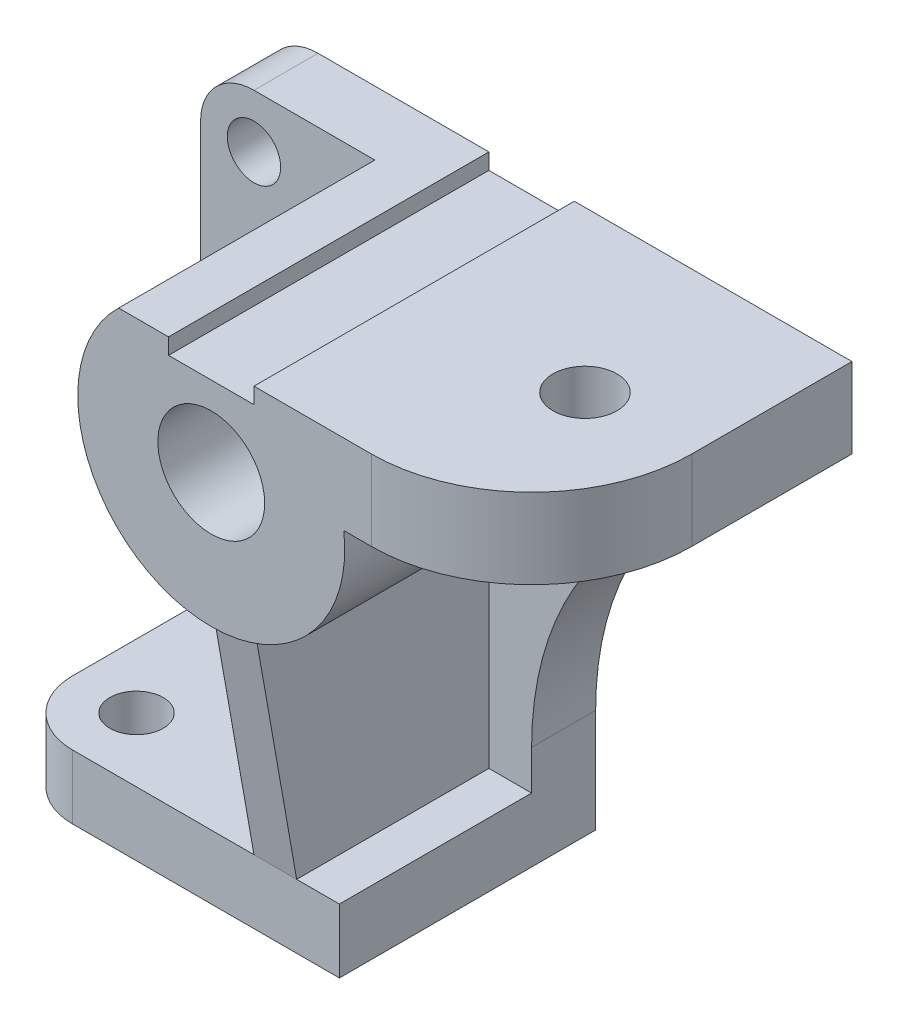
from build123d import *

# Parameters (mm, degrees)
SKETCH1_R           = 5
BOSS_EXTRUDE1_DEPTH = 12
SKETCH2_R           = 5
BOSS_EXTRUDE2_DEPTH = 12
BOSS_EXTRUDE3_DEPTH = 48
FILLET1_R           = 30
SKETCH6_R           = 10
CUT_EXTRUDE1_DEPTH  = 61
SKETCH7_W           = 16
SKETCH7_H           = 3
CUT_EXTRUDE2_DEPTH  = 61
CUT_EXTRUDE3_REACH  = 102
SKETCH9_R           = 6
RIB9_REACH          = 62
SKETCH8_WALL_W      = 167.694197534
SKETCH8_WALL_H      = 8


with BuildPart() as part:
    # Sketch1 → Boss-Extrude1 (new body)
    with BuildSketch(Plane.XY):
        with BuildLine():
            Line((10, 100), (110, 100))
            Line((110, 100), (110, 85))
            Line((110, 85), (95, 85))
            Line((95, 85), (95, 73))
            ThreePointArc((95, 73), (70.911840902, 50.882552147), (62, 19.418286702))
            Line((62, 19.418286702), (62, 0))
            Line((62, 0), (0, 0))
            Line((0, 0), (0, 90))
            ThreePointArc((0, 90), (2.928932188, 97.071067812), (10, 100))
        make_face()
        with Locations((10, 90)):
            Circle(SKETCH1_R, mode=Mode.SUBTRACT)
    extrude(amount=BOSS_EXTRUDE1_DEPTH)

    # Sketch2 → Boss-Extrude2 (add)
    with BuildSketch(Plane.XZ):
        with BuildLine():
            Line((62, 12), (62, 48))
            Line((62, 48), (12, 48))
            ThreePointArc((12, 48), (3.514718626, 44.485281374), (0, 36))
            Line((0, 36), (0, 12))
            Line((0, 12), (62, 12))
        make_face()
        with Locations(Location((12, 36, 0), (0, 0, 270))):  # turned: the seam where the file's is
            Circle(SKETCH2_R, mode=Mode.SUBTRACT)
    extrude(amount=-BOSS_EXTRUDE2_DEPTH)

    # Sketch5 → Boss-Extrude3 (add)
    with BuildSketch(Plane.XY.offset(12)):
        with BuildLine():
            Line((32.650648427, 100), (110, 100))
            Line((110, 100), (110, 85))
            Line((110, 85), (74.819347292, 85))
            ThreePointArc((74.819347292, 85), (41.621443501, 58.445811604), (32.650648427, 100))
        make_face()
    extrude(amount=BOSS_EXTRUDE3_DEPTH)

    # Fillet1
    fillet1_edges = [part.edges().sort_by_distance(p)[0] for p in [
        (110, 92.5, 60),
    ]]
    fillet(fillet1_edges, radius=FILLET1_R)

    # Sketch6 → Cut-Extrude1 (cut, through all)
    with BuildSketch(Plane.XY.offset(60)):
        with Locations((50, 82)):
            Circle(SKETCH6_R)
    extrude(amount=-CUT_EXTRUDE1_DEPTH, mode=Mode.SUBTRACT)

    # Sketch7 → Cut-Extrude2 (cut, through all)
    with BuildSketch(Plane.XY.offset(60)):
        with Locations((50, 98.5)):
            Rectangle(SKETCH7_W, SKETCH7_H)
    extrude(amount=-CUT_EXTRUDE2_DEPTH, mode=Mode.SUBTRACT)

    # Sketch9 → Cut-Extrude3 (cut, up to next)
    with BuildSketch(Plane(origin=(0, 100, 0), x_dir=(1, 0, 0), z_dir=(0, 1, 0)), mode=Mode.PRIVATE) as cut_extrude3_sk1:
        with Locations(Location((90, -30, 0), (0, 0, 270))):  # turned: the seam where the file's is
            Circle(SKETCH9_R)
    cut_extrude3_tool1 = extrude(cut_extrude3_sk1.sketch, amount=-CUT_EXTRUDE3_REACH, mode=Mode.PRIVATE) & part.part
    add(cut_extrude3_tool1.solids().sort_by_distance((90, 100, 30))[0], mode=Mode.SUBTRACT)

    # Sketch8 wall → Rib9 (add, up to next)
    with BuildSketch(Plane(origin=(50, 34.5, 51.967357066), x_dir=(0, 0.984807753, 0.173648178), z_dir=(0, -0.173648178, 0.984807753)), mode=Mode.PRIVATE) as rib9_sk1:
        Rectangle(SKETCH8_WALL_W, SKETCH8_WALL_H)
    rib9_tool1 = extrude(rib9_sk1.sketch, amount=-RIB9_REACH, mode=Mode.PRIVATE) - part.part
    add(rib9_tool1.solids().sort_by_distance((50, 34.5, 51.967357066))[0])


solid = part.part
